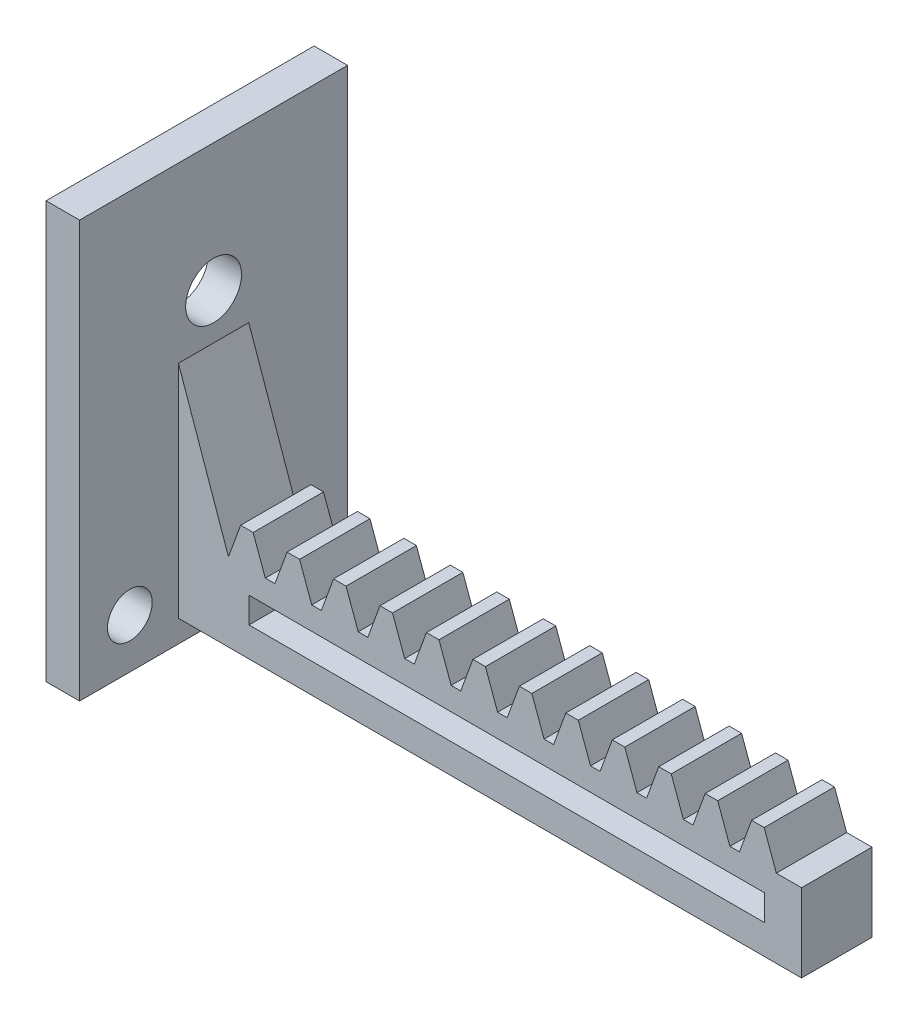
from build123d import *

# Parameters (mm, degrees)
SKETCH1_W           = 55.8
SKETCH1_H           = 7
BOSS_EXTRUDE2_DEPTH = 6.3
SKETCH2_W           = 46.18
SKETCH2_H           = 2.31
CUT_EXTRUDE1_DEPTH  = 6.3
BOSS_EXTRUDE3_DEPTH = 6.3
SKETCH5_W           = 3
SKETCH5_H           = 24
BOSS_EXTRUDE4_DEPTH = 35.3
SKETCH6_R           = 2
SKETCH6_R_2         = 2.5
CUT_EXTRUDE2_DEPTH  = 40
BOSS_EXTRUDE5_DEPTH = 6.3
SKETCH8_W           = 3
SKETCH8_H           = 24
BOSS_EXTRUDE6_DEPTH = 2


with BuildPart() as part:
    # Sketch1 → Boss-Extrude2 (new body)
    with BuildSketch(Plane.XY):
        Rectangle(SKETCH1_W, SKETCH1_H)
    extrude(amount=BOSS_EXTRUDE2_DEPTH)

    # Sketch2 → Cut-Extrude1 (cut)
    with BuildSketch(Plane.XY.offset(6.3)):
        with Locations((1.51, 0.295)):
            Rectangle(SKETCH2_W, SKETCH2_H)
    extrude(amount=-CUT_EXTRUDE1_DEPTH, mode=Mode.SUBTRACT)

    # Sketch3 → Boss-Extrude3 (add)
    with BuildSketch(Plane.XY.offset(6.3)):
        Polygon((-23.42, 3.5), (-22.331, 6.494), (-21.209, 6.494), (-20.12, 3.5), align=None)
        Polygon((-19.26, 3.5), (-15.96, 3.5), (-17.049, 6.494), (-18.171, 6.494), align=None)
        Polygon((-15.1, 3.5), (-11.8, 3.5), (-12.889, 6.494), (-14.011, 6.494), align=None)
        Polygon((-10.94, 3.5), (-7.64, 3.5), (-8.729, 6.494), (-9.851, 6.494), align=None)
        Polygon((-6.78, 3.5), (-3.48, 3.5), (-4.569, 6.494), (-5.691, 6.494), align=None)
        Polygon((-2.62, 3.5), (0.68, 3.5), (-0.409, 6.494), (-1.531, 6.494), align=None)
        Polygon((1.54, 3.5), (4.84, 3.5), (3.751, 6.494), (2.629, 6.494), align=None)
        Polygon((5.7, 3.5), (9, 3.5), (7.911, 6.494), (6.789, 6.494), align=None)
        Polygon((9.86, 3.5), (13.16, 3.5), (12.071, 6.494), (10.949, 6.494), align=None)
        Polygon((14.02, 3.5), (17.32, 3.5), (16.231, 6.494), (15.109, 6.494), align=None)
        Polygon((18.18, 3.5), (21.48, 3.5), (20.391, 6.494), (19.269, 6.494), align=None)
        Polygon((22.34, 3.5), (25.64, 3.5), (24.551, 6.494), (23.429, 6.494), align=None)
    extrude(amount=-BOSS_EXTRUDE3_DEPTH)

    # Sketch5 → Boss-Extrude4 (add)
    with BuildSketch(Plane(origin=(0, -3.5, 0), x_dir=(-1, 0, 0), z_dir=(0, -1, 0))):
        with Locations((29.4, -3.15)):
            Rectangle(SKETCH5_W, SKETCH5_H)
    extrude(amount=-BOSS_EXTRUDE4_DEPTH)

    # Sketch6 → Cut-Extrude2 (cut)
    with BuildSketch(Plane(origin=(-27.9, 0, 0), x_dir=(0, 0, -1), z_dir=(1, 0, 0))):
        with Locations((4.35, -1.08)):
            Circle(SKETCH6_R)
        with Locations((-10.65, -1.08)):
            Circle(SKETCH6_R)
        with Locations((-3.15, 20.34)):
            Circle(SKETCH6_R_2)
    extrude(amount=-CUT_EXTRUDE2_DEPTH, mode=Mode.SUBTRACT)

    # Sketch7 → Boss-Extrude5 (add)
    with BuildSketch(Plane(origin=(0, 0, 0), x_dir=(-1, 0, 0), z_dir=(0, 0, -1))):
        Polygon((23.42, 3.5), (27.9, 16.274768446), (27.9, 8.809175652), (27.9, 3.5), align=None)
    extrude(amount=-BOSS_EXTRUDE5_DEPTH)

    # Sketch8 → Boss-Extrude6 (add)
    with BuildSketch(Plane.XZ.offset(3.5)):
        with Locations((-29.4, 3.15)):
            Rectangle(SKETCH8_W, SKETCH8_H)
    extrude(amount=BOSS_EXTRUDE6_DEPTH)


solid = part.part
